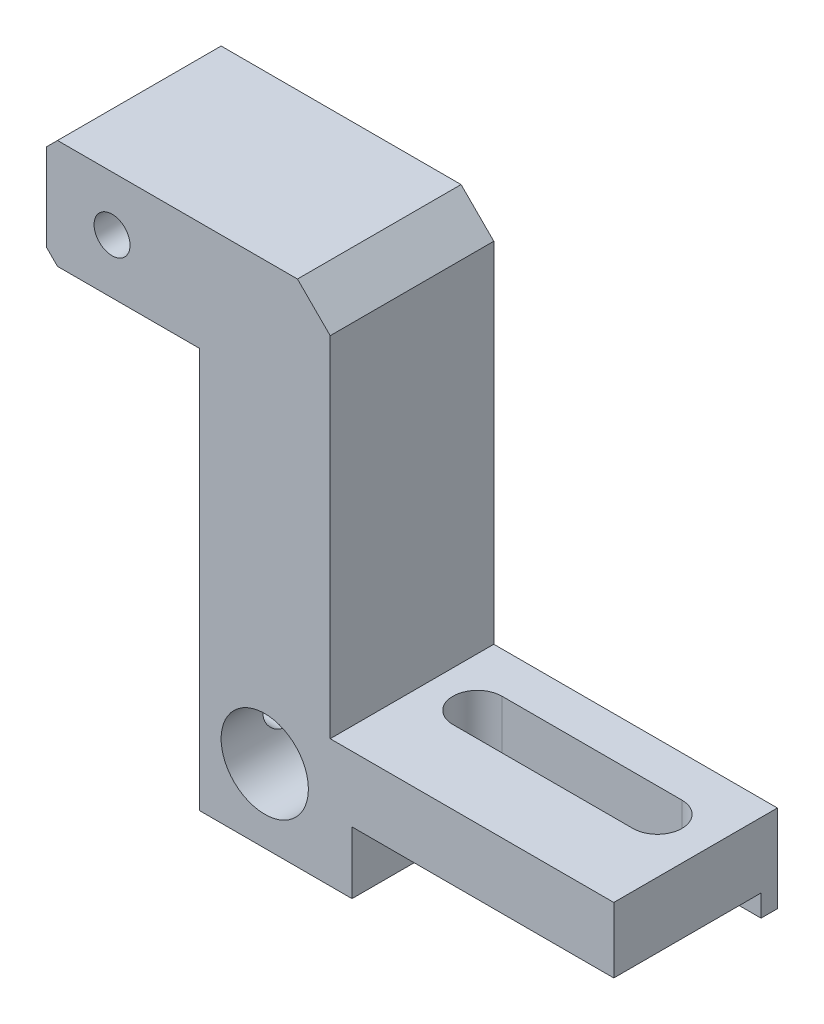
from build123d import *

# Parameters (mm, degrees)
SKETCH1_R                  = 4
BOSS_EXTRUDE1_DEPTH        = 15
SKETCH2_W                  = 22
SKETCH2_H                  = 1.5
BOSS_EXTRUDE2_DEPTH        = 2
CUT_EXTRUDE1_DEPTH         = 50.923615123
M4X0_7_TAPPED_HOLE1_REACH  = 58.902
M4X0_7_TAPPED_HOLE1_BORE_R = 1.65
M4X0_7_TAPPED_HOLE2_D      = 3.3
M4X0_7_TAPPED_HOLE2_DEPTH  = 8
M4X0_7_TAPPED_HOLE2_TIP    = 0.991420021
CHAMFER1_SIZE              = 1
CHAMFER2_SIZE              = 3


with BuildPart() as part:
    # Sketch1 → Boss-Extrude1 (new body)
    with BuildSketch(Plane.XY):
        Polygon((-19.714285714, 7.091836735), (6.285714286, 7.091836735), (6.285714286, -27.908163265), (32.285714286, -27.908163265), (32.285714286, -33.908163265), (8.285714286, -33.908163265), (8.285714286, -39.608163265), (-5.714285714, -39.608163265), (-5.714285714, -2.908163265), (-19.714285714, -2.908163265), align=None)
        with Locations((0.285714286, -32.908163265)):
            Circle(SKETCH1_R, mode=Mode.SUBTRACT)
    extrude(amount=BOSS_EXTRUDE1_DEPTH)

    # Sketch2 → Boss-Extrude2 (add)
    with BuildSketch(Plane.XZ.offset(33.908163265)):
        with Locations((21.285714286, 0.75)):
            Rectangle(SKETCH2_W, SKETCH2_H)
    extrude(amount=BOSS_EXTRUDE2_DEPTH)

    # Sketch3 → Cut-Extrude1 (cut, through all)
    with BuildSketch(Plane(origin=(0, -27.908163265, 0), x_dir=(1, 0, 0), z_dir=(0, 1, 0))):
        with BuildLine():
            Line((10.785714286, -3.75), (27.285714286, -3.75))
            ThreePointArc((27.285714286, -3.75), (29.535714286, -6), (27.285714286, -8.25))
            Line((27.285714286, -8.25), (10.785714286, -8.25))
            ThreePointArc((10.785714286, -8.25), (8.535714286, -6), (10.785714286, -3.75))
        make_face()
    extrude(amount=-CUT_EXTRUDE1_DEPTH, mode=Mode.SUBTRACT)

    # M4x0.7 Tapped Hole1 bore → M4x0.7 Tapped Hole1 (cut, up to next)
    with BuildSketch(Plane.ZY.offset(5.714285714), mode=Mode.PRIVATE) as m4x0_7_tapped_hole1_sk1:
        with Locations((9.5, -32.908163265)):
            Circle(M4X0_7_TAPPED_HOLE1_BORE_R)
    m4x0_7_tapped_hole1_tool1 = extrude(m4x0_7_tapped_hole1_sk1.sketch, amount=-M4X0_7_TAPPED_HOLE1_REACH, mode=Mode.PRIVATE) & part.part
    add(m4x0_7_tapped_hole1_tool1.solids().sort_by_distance((-5.714286, -32.908163, 9.5))[0], mode=Mode.SUBTRACT)

    # M4x0.7 Tapped Hole2
    with Locations(Plane.XY.offset(15)):
        with Locations((-13.714285714, 2.091836735)):
            Hole(M4X0_7_TAPPED_HOLE2_D / 2, depth=M4X0_7_TAPPED_HOLE2_DEPTH)
            with Locations((0, 0, -(M4X0_7_TAPPED_HOLE2_DEPTH + M4X0_7_TAPPED_HOLE2_TIP / 2))):  # 118° drill point
                Cone(0, M4X0_7_TAPPED_HOLE2_D / 2, M4X0_7_TAPPED_HOLE2_TIP, mode=Mode.SUBTRACT)

    # Chamfer1
    chamfer1_edges = [part.edges().sort_by_distance(p)[0] for p in [
        (-19.714285714, 7.091836735, 7.5),
        (-19.714285714, -2.908163265, 7.5),
    ]]
    chamfer(chamfer1_edges, length=CHAMFER1_SIZE)

    # Chamfer2
    chamfer2_edges = [part.edges().sort_by_distance(p)[0] for p in [
        (6.285714286, 7.091836735, 7.5),
    ]]
    chamfer(chamfer2_edges, length=CHAMFER2_SIZE)


solid = part.part
